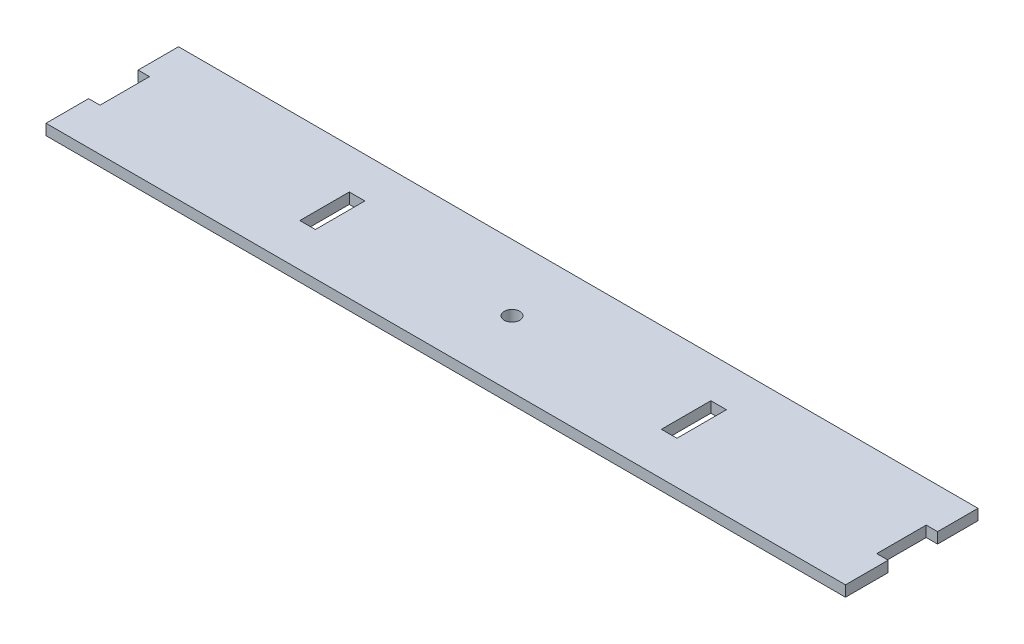
from build123d import *

# Parameters (mm, degrees)
SKETCH1_W           = 355.6
SKETCH1_H           = 58.42
BOSS_EXTRUDE1_DEPTH = 4.7625
SKETCH2_W           = 6.858
SKETCH2_H           = 21.806929344
SKETCH2_W_2         = 6.35
SKETCH2_H_2         = 21.298929344
CUT_EXTRUDE1_DEPTH  = 181.246346721
SKETCH3_W           = 1.5875
SKETCH3_H           = 17.817070656
SKETCH3_H_2         = 18.796
CUT_EXTRUDE2_DEPTH  = 181.246346721
SKETCH4_W           = 0.3175
SKETCH4_H           = 21.806929344
BOSS_EXTRUDE2_DEPTH = 4.7625
SKETCH5_W           = 0.3175
SKETCH5_H           = 21.806929344
CUT_EXTRUDE3_DEPTH  = 179.68058278
SKETCH6_R           = 3.429
CUT_EXTRUDE4_DEPTH  = 179.68058278


with BuildPart() as part:
    # Sketch1 → Boss-Extrude1 (new body)
    with BuildSketch(Plane(origin=(0, 0, 0), x_dir=(1, 0, 0), z_dir=(0, 1, 0))):
        Rectangle(SKETCH1_W, SKETCH1_H)
    extrude(amount=BOSS_EXTRUDE1_DEPTH)

    # Sketch2 → Cut-Extrude1 (cut, through all)
    with BuildSketch(Plane(origin=(0, 0, 0), x_dir=(-1, 0, 0), z_dir=(0, -1, 0))):
        with Locations((174.625, 0.489464672)):
            Rectangle(SKETCH2_W, SKETCH2_H)
        with Locations((174.625, 0.489464672)):
            Rectangle(SKETCH2_W_2, SKETCH2_H_2, mode=Mode.SUBTRACT)
        with Locations((79.375, 0.489464672)):
            Rectangle(SKETCH2_W, SKETCH2_H)
        with Locations((79.375, 0.489464672)):
            Rectangle(SKETCH2_W_2, SKETCH2_H_2, mode=Mode.SUBTRACT)
        with Locations((-79.375, 0.489464672)):
            Rectangle(SKETCH2_W, SKETCH2_H)
        with Locations((-79.375, 0.489464672)):
            Rectangle(SKETCH2_W_2, SKETCH2_H_2, mode=Mode.SUBTRACT)
        with Locations((-174.625, 0.489464672)):
            Rectangle(SKETCH2_W, SKETCH2_H)
        with Locations((-174.625, 0.489464672)):
            Rectangle(SKETCH2_W_2, SKETCH2_H_2, mode=Mode.SUBTRACT)
    extrude(amount=-CUT_EXTRUDE1_DEPTH, mode=Mode.SUBTRACT)


with BuildPart() as cut_extrude1_kept_piece:
    # of the separate pieces the step leaves, the one the design keeps (cut_extrude1_pieces_kept)
    add(part.part.solids().sort_by_distance((-177.8, 0, -29.21))[0])

    # Sketch3 → Cut-Extrude2 (cut, through all)
    with BuildSketch(Plane.XZ):
        with Locations((177.00625, -20.301464672)):
            Rectangle(SKETCH3_W, SKETCH3_H)
        with Locations((177.00625, 19.812)):
            Rectangle(SKETCH3_W, SKETCH3_H_2)
        with Locations((-177.00625, -20.301464672)):
            Rectangle(SKETCH3_W, SKETCH3_H)
        with Locations((-177.00625, 19.812)):
            Rectangle(SKETCH3_W, SKETCH3_H_2)
    extrude(amount=-CUT_EXTRUDE2_DEPTH, mode=Mode.SUBTRACT)

    # Sketch4 → Boss-Extrude2 (add)
    with BuildSketch(Plane.XZ):
        with Locations((76.10475, -0.489464672)):
            Rectangle(SKETCH4_W, SKETCH4_H)
        with Locations((-76.10475, -0.489464672)):
            Rectangle(SKETCH4_W, SKETCH4_H)
    extrude(amount=-BOSS_EXTRUDE2_DEPTH)

    # Sketch5 → Cut-Extrude3 (cut, through all)
    with BuildSketch(Plane.XZ):
        with Locations((-82.96275, -0.489464672)):
            Rectangle(SKETCH5_W, SKETCH5_H)
        with Locations((82.96275, -0.489464672)):
            Rectangle(SKETCH5_W, SKETCH5_H)
    extrude(amount=-CUT_EXTRUDE3_DEPTH, mode=Mode.SUBTRACT)

    # Sketch6 → Cut-Extrude4 (cut, through all)
    with BuildSketch(Plane.XZ):
        with Locations(Location((0, 0, 0), (0, 0, 270))):
            Circle(SKETCH6_R)
    extrude(amount=-CUT_EXTRUDE4_DEPTH, mode=Mode.SUBTRACT)


solid = cut_extrude1_kept_piece.part
